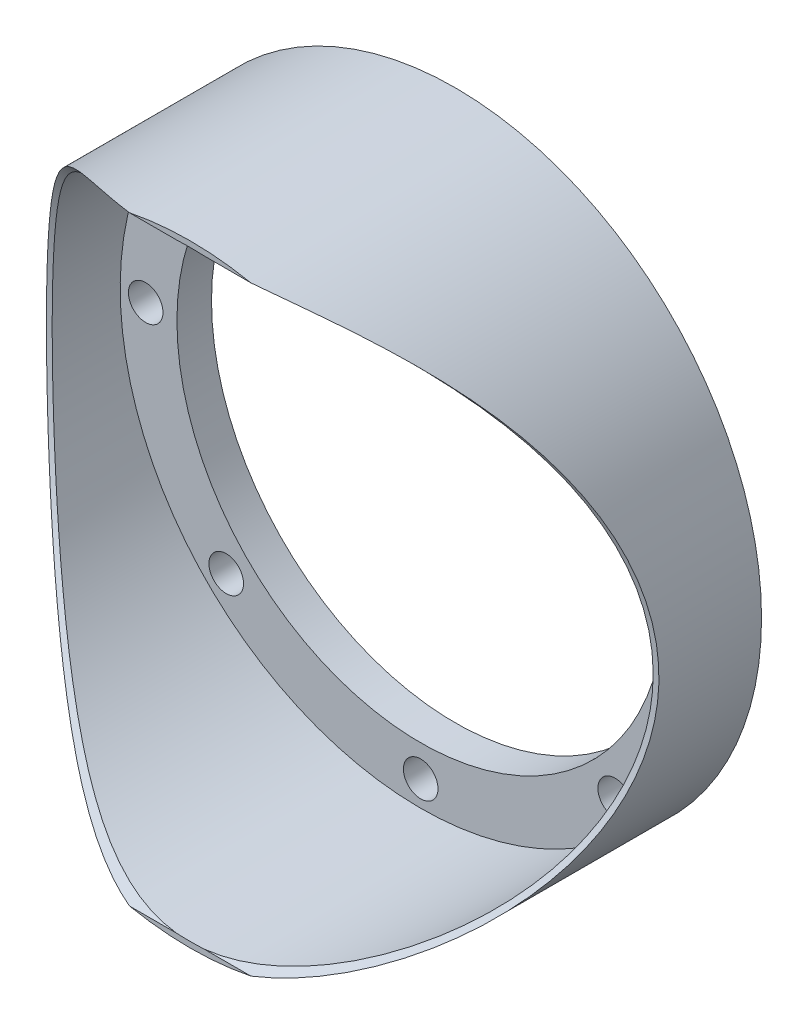
from build123d import *

# Parameters (mm, degrees)
SKETCH1_R           = 265.7
SKETCH1_R_2         = 211.5
SKETCH1_R_3         = 20
SKETCH1_R_4         = 5
EXTRUDE1_DEPTH      = 5
SKETCH2_R           = 265.7
SKETCH2_R_2         = 15
SKETCH2_R_3         = 211.5
EXTRUDE2_DEPTH      = 25
SKETCH3_R           = 265.7
SKETCH3_R_2         = 260.7
EXTRUDE3_DEPTH      = 200
SKETCH4_R           = 311
EXTRUDE4_DEPTH      = 266.7
EXTRUDE4_DEPTH_BACK = 266.7


with BuildPart() as part:
    # Sketch1 → Extrude1 (new body)
    with BuildSketch(Plane.XY):
        Circle(SKETCH1_R)
        Circle(SKETCH1_R_2, mode=Mode.SUBTRACT)
        with Locations((238.6, 0)):
            Circle(SKETCH1_R_3, mode=Mode.SUBTRACT)
        with Locations((168.715677991, 168.715677991)):
            Circle(SKETCH1_R_3, mode=Mode.SUBTRACT)
        with Locations((0, 238.6)):
            Circle(SKETCH1_R_3, mode=Mode.SUBTRACT)
        with Locations((-168.715677991, 168.715677991)):
            Circle(SKETCH1_R_3, mode=Mode.SUBTRACT)
        with Locations((-238.6, 0)):
            Circle(SKETCH1_R_3, mode=Mode.SUBTRACT)
        with Locations((-168.715677991, -168.715677991)):
            Circle(SKETCH1_R_3, mode=Mode.SUBTRACT)
        with Locations((0, -238.6)):
            Circle(SKETCH1_R_3, mode=Mode.SUBTRACT)
        with Locations((168.715677991, -168.715677991)):
            Circle(SKETCH1_R_3, mode=Mode.SUBTRACT)
        with Locations((230.469902153, 61.754224161)):
            Circle(SKETCH1_R_4, mode=Mode.SUBTRACT)
        with Locations((-230.469902153, 61.754224161)):
            Circle(SKETCH1_R_4, mode=Mode.SUBTRACT)
        with Locations((-91.308266962, -220.437656457)):
            Circle(SKETCH1_R_4, mode=Mode.SUBTRACT)
    extrude(amount=EXTRUDE1_DEPTH)

    # Sketch2 → Extrude2 (add)
    with BuildSketch(Plane.XY.offset(5)):
        Circle(SKETCH2_R)
        with Locations((238.6, 0)):
            Circle(SKETCH2_R_2, mode=Mode.SUBTRACT)
        with Locations((168.715677991, 168.715677991)):
            Circle(SKETCH2_R_2, mode=Mode.SUBTRACT)
        with Locations((0, 238.6)):
            Circle(SKETCH2_R_2, mode=Mode.SUBTRACT)
        with Locations((-168.715677991, 168.715677991)):
            Circle(SKETCH2_R_2, mode=Mode.SUBTRACT)
        with Locations((-238.6, 0)):
            Circle(SKETCH2_R_2, mode=Mode.SUBTRACT)
        with Locations((-168.715677991, -168.715677991)):
            Circle(SKETCH2_R_2, mode=Mode.SUBTRACT)
        with Locations((0, -238.6)):
            Circle(SKETCH2_R_2, mode=Mode.SUBTRACT)
        with Locations((168.715677991, -168.715677991)):
            Circle(SKETCH2_R_2, mode=Mode.SUBTRACT)
        Circle(SKETCH2_R_3, mode=Mode.SUBTRACT)
    extrude(amount=EXTRUDE2_DEPTH)

    # Sketch3 → Extrude3 (add)
    with BuildSketch(Plane.XY.offset(30)):
        Circle(SKETCH3_R)
        Circle(SKETCH3_R_2, mode=Mode.SUBTRACT)
    extrude(amount=EXTRUDE3_DEPTH)

    # Sketch4 → Extrude4 (cut, two sides)
    with BuildSketch(Plane(origin=(0, 0, 0), x_dir=(0, 0, -1), z_dir=(1, 0, 0))) as extrude4_sk:
        with Locations((-400, 0)):
            Circle(SKETCH4_R)
    extrude(amount=EXTRUDE4_DEPTH, mode=Mode.SUBTRACT)
    extrude(extrude4_sk.sketch, amount=-EXTRUDE4_DEPTH_BACK, mode=Mode.SUBTRACT)


solid = part.part
